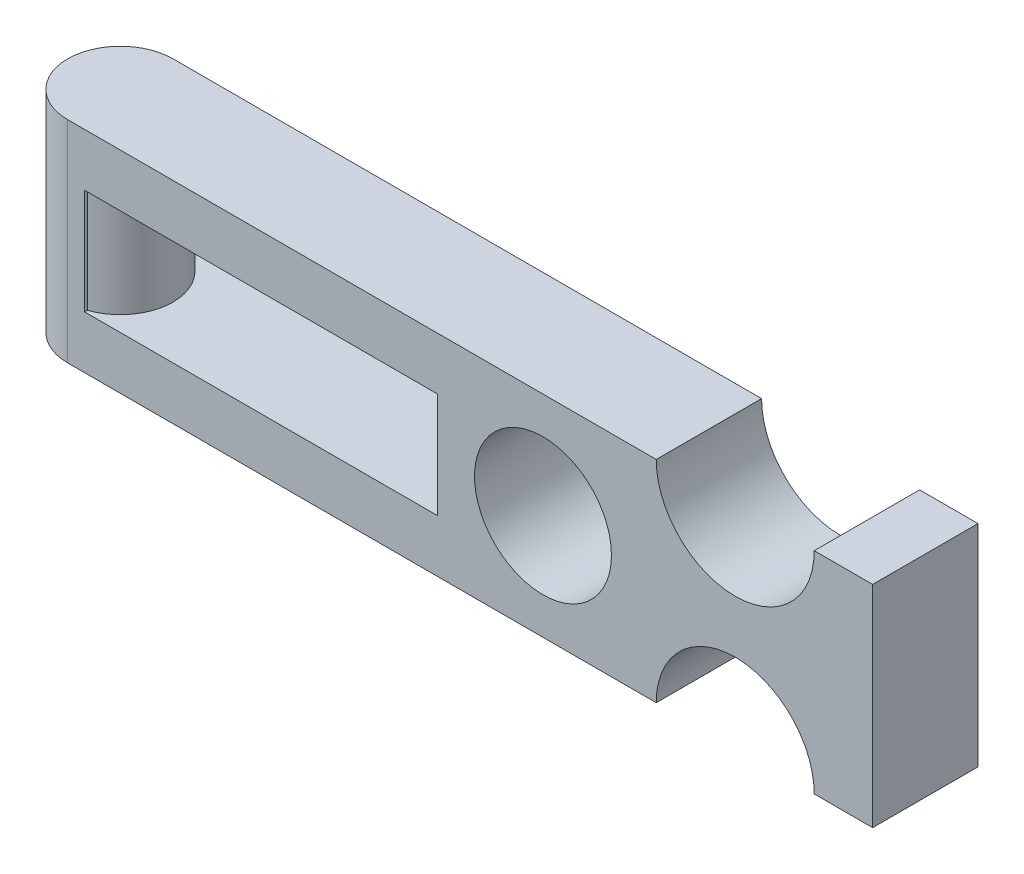
from build123d import *

# Parameters (mm, degrees)
SKETCH1_R           = 8.255
SKETCH1_W           = 42.529452224
SKETCH1_H           = 12.7
BOSS_EXTRUDE1_DEPTH = 12.7
SKETCH2_R           = 6.35
BOSS_EXTRUDE2_DEPTH = 25.4


with BuildPart() as part:
    # Sketch1 → Boss-Extrude1 (new body)
    with BuildSketch(Plane.XY):
        with BuildLine():
            Line((89.999184934, 12.7), (97.04, 12.7))
            Line((97.04, 12.7), (97.04, -12.7))
            Line((97.04, -12.7), (89.999184934, -12.7))
            ThreePointArc((89.999184934, -12.7), (80.474184934, -3.175), (70.949184934, -12.7))
            Line((70.949184934, -12.7), (0, -12.7))
            Line((0, -12.7), (0, 12.7))
            Line((0, 12.7), (70.949184934, 12.7))
            ThreePointArc((70.949184934, 12.7), (80.474184934, 3.175), (89.999184934, 12.7))
        make_face()
        with Locations((57.297, 0)):
            Circle(SKETCH1_R, mode=Mode.SUBTRACT)
        with Locations((23.301842553, 0)):
            Rectangle(SKETCH1_W, SKETCH1_H, mode=Mode.SUBTRACT)
    extrude(amount=BOSS_EXTRUDE1_DEPTH)

    # Sketch2 → Boss-Extrude2 (add, through all)
    with BuildSketch(Plane(origin=(0, 12.7, 0), x_dir=(1, 0, 0), z_dir=(0, 1, 0))):
        with Locations((0, -6.35)):
            Circle(SKETCH2_R)
    extrude(amount=-BOSS_EXTRUDE2_DEPTH)


solid = part.part
